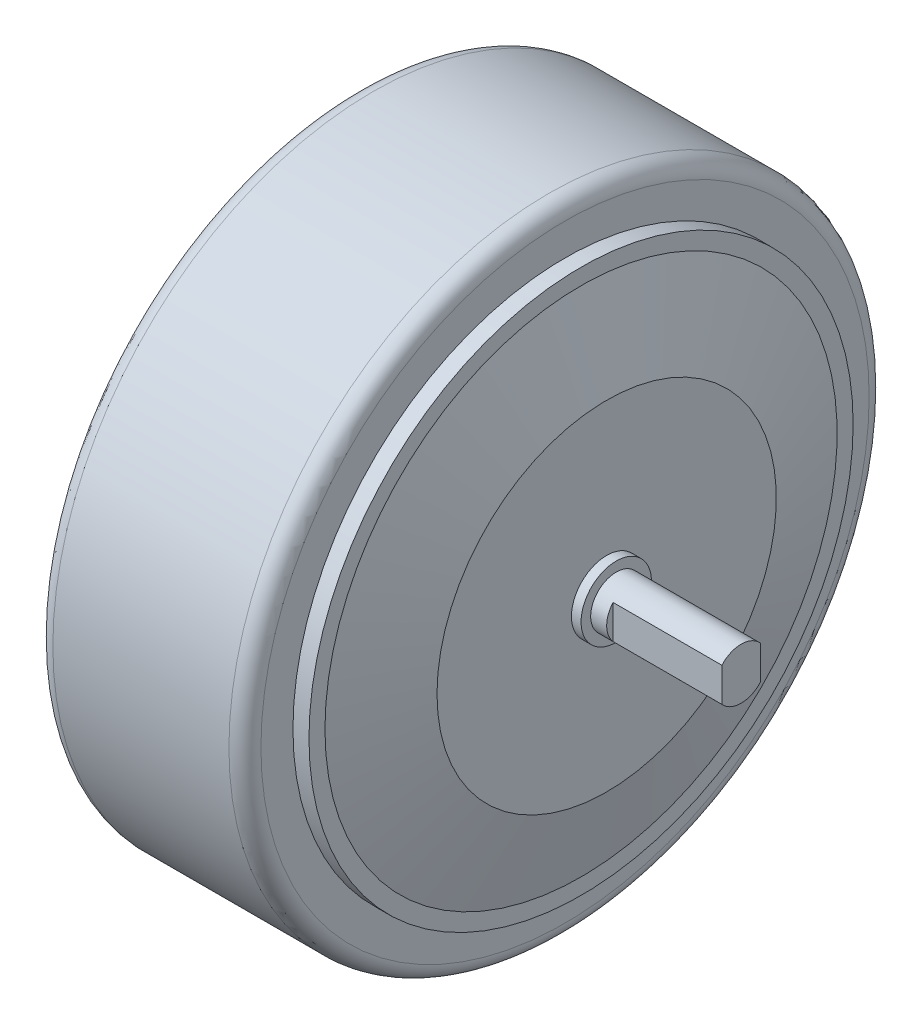
from build123d import *

# Parameters (mm, degrees)
FILLET_1_R           = 5
CUT_EXTRUDE_START    = -53.5
SKETCH_2_OUTSIDE_W   = 268.52
SKETCH_2_OUTSIDE_H   = 268.52
CUT_EXTRUDE_1_DEPTH  = 35
CUT_EXTRUDE_START_2  = 53.5
SKETCH_2_2_OUTSIDE_W = 268.52
SKETCH_2_2_OUTSIDE_H = 268.52
CUT_EXTRUDE_2_DEPTH  = 35


with BuildPart() as part:
    # Эскиз1 → Повернуть1 (revolve)
    with BuildSketch(Plane.XY):
        Polygon((-32.5, 100), (32.5, 100), (32.5, 85), (37.5, 85), (37.5, 80), (45.5, 53), (45.5, 11), (48.5, 11), (48.5, 8), (87.5, 8), (87.5, 0), (-87.5, 0), (-87.5, 8), (-48.5, 8), (-48.5, 11), (-45.5, 11), (-45.5, 53), (-37.5, 80), (-37.5, 85), (-32.5, 85), align=None)
    revolve(axis=Axis((-1100.903674864, 0, 0), (1, 0, 0)))

    # Скругление1
    fillet_1_edges = [part.edges().sort_by_distance(p)[0] for p in [
        (32.5, -100, 0),
        (-32.5, -100, 0),
    ]]
    fillet(fillet_1_edges, radius=FILLET_1_R)

    # Эскиз2 outside → Вырез-Вытянуть1 (cut, through all)
    with BuildSketch(Plane(origin=(0, 0, 0), x_dir=(0, 0, -1), z_dir=(1, 0, 0)).offset(CUT_EXTRUDE_START)):
        Rectangle(SKETCH_2_OUTSIDE_W, SKETCH_2_OUTSIDE_H)
        with BuildLine():
            Line((-6, 5.291502622), (-6, -5.291502622))
            ThreePointArc((-6, -5.291502622), (0, -8), (6, -5.291502622))
            Line((6, -5.291502622), (6, 5.291502622))
            ThreePointArc((6, 5.291502622), (0, 8), (-6, 5.291502622))
        make_face(mode=Mode.SUBTRACT)
    extrude(amount=-CUT_EXTRUDE_1_DEPTH, mode=Mode.SUBTRACT)

    # Эскиз2<2> outside → Вырез-Вытянуть2 (cut, through all)
    with BuildSketch(Plane(origin=(0, 0, 0), x_dir=(0, 0, -1), z_dir=(1, 0, 0)).offset(CUT_EXTRUDE_START_2)):
        Rectangle(SKETCH_2_2_OUTSIDE_W, SKETCH_2_2_OUTSIDE_H)
        with BuildLine():
            Line((-6, 5.291502622), (-6, -5.291502622))
            ThreePointArc((-6, -5.291502622), (0, -8), (6, -5.291502622))
            Line((6, -5.291502622), (6, 5.291502622))
            ThreePointArc((6, 5.291502622), (0, 8), (-6, 5.291502622))
        make_face(mode=Mode.SUBTRACT)
    extrude(amount=CUT_EXTRUDE_2_DEPTH, mode=Mode.SUBTRACT)


solid = part.part
